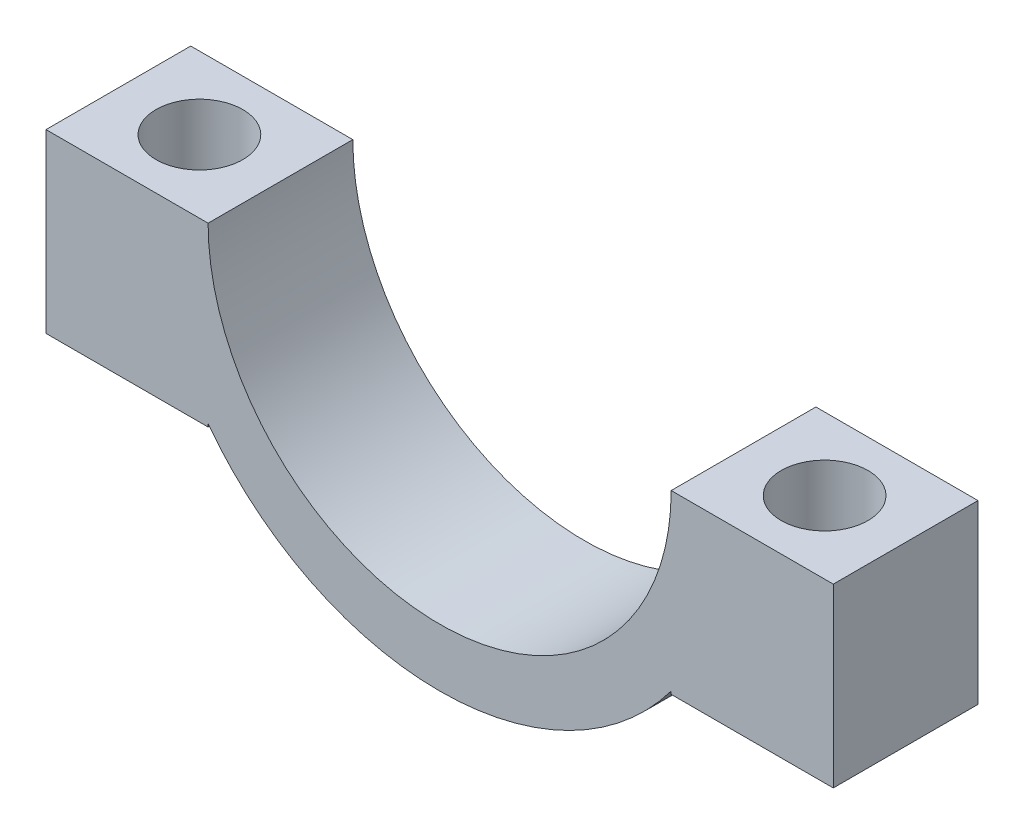
from build123d import *

# Parameters (mm, degrees)
BOSS_EXTRUDE1_DEPTH = 5
SKETCH3_R           = 1.5
CUT_EXTRUDE1_DEPTH  = 10


with BuildPart() as part:
    # Sketch2 → Boss-Extrude1 (new body)
    with BuildSketch(Plane.XY):
        with BuildLine():
            ThreePointArc((-8, -6), (0, -10), (8, -6))
            Line((8, -6), (8, -6.1))
            Line((8, -6.1), (13.6, -6.1))
            Line((13.6, -6.1), (13.6, 0))
            Line((13.6, 0), (8, 0))
            ThreePointArc((8, 0), (0, -8), (-8, 0))
            Line((-8, 0), (-13.6, 0))
            Line((-13.6, 0), (-13.6, -6.1))
            Line((-13.6, -6.1), (-8, -6.1))
            Line((-8, -6.1), (-8, -6))
        make_face()
    extrude(amount=BOSS_EXTRUDE1_DEPTH)

    # Sketch3 → Cut-Extrude1 (cut)
    with BuildSketch(Plane(origin=(0, 0, 0), x_dir=(1, 0, 0), z_dir=(0, 1, 0))):
        with Locations((-10.8, -2.5)):
            Circle(SKETCH3_R)
        with Locations((10.8, -2.5)):
            Circle(SKETCH3_R)
    extrude(amount=-CUT_EXTRUDE1_DEPTH, mode=Mode.SUBTRACT)


solid = part.part
